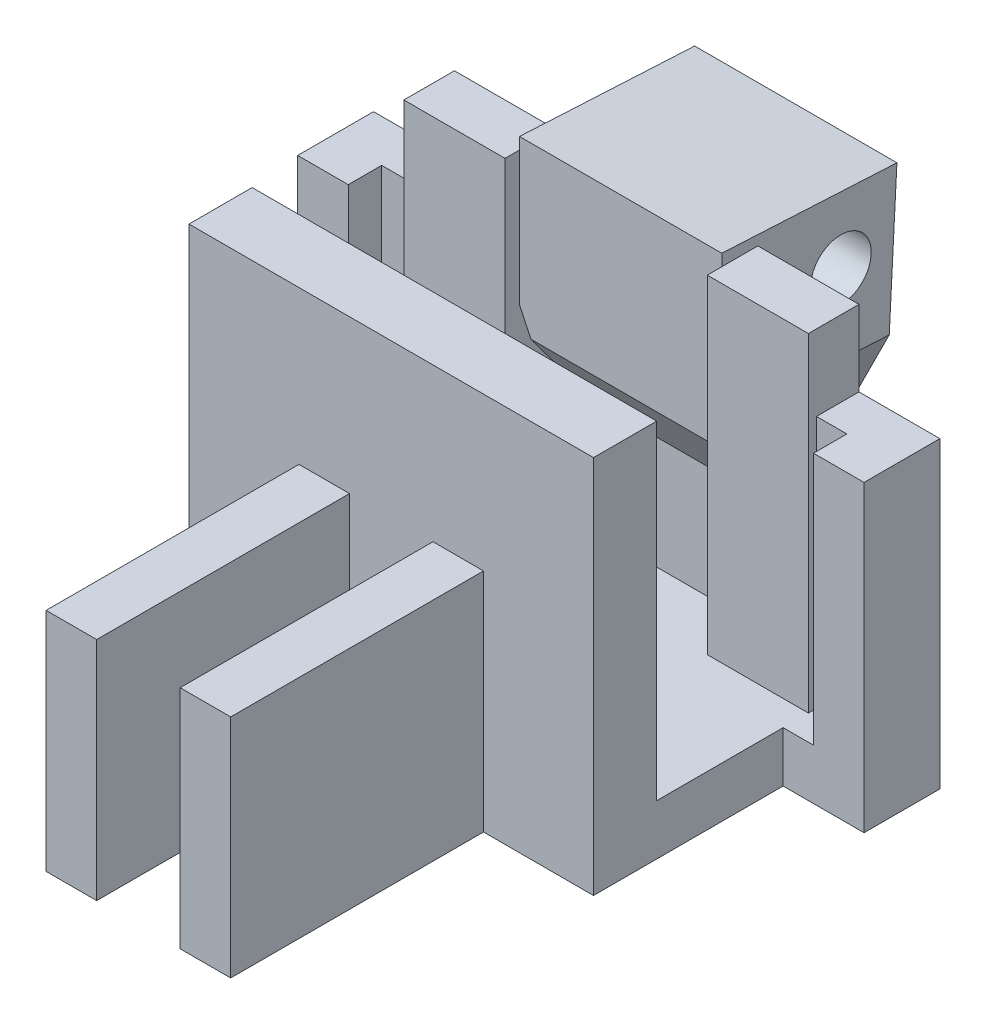
from build123d import *

# Parameters (mm, degrees)
SKETCH_1_W          = 16
SKETCH_1_H          = 6
EXTRUDE_1_DEPTH     = 2
SKETCH_1_3_W        = 16
SKETCH_1_3_H        = 2
SKETCH_1_3_H_2      = 2.5
EXTRUDE_2_DEPTH     = 15
SKETCH_2_W          = 8
SKETCH_2_H          = 26
CUT_EXTRUDE_1_DEPTH = 2
EXTRUDE_3_DEPTH     = 2.5
EXTRUDE_4_DEPTH     = 5
EXTRUDE_5_DEPTH     = 1.5
CUT_EXTRUDE_START   = -6.633865
CUT_EXTRUDE_3_DEPTH = 6.633865
SKETCH_8_R          = 1.2
CUT_EXTRUDE_4_DEPTH = 8
SKETCH_9_W          = 1.2
SKETCH_9_H          = 1.320432063
EXTRUDE_6_DEPTH     = 2
EXTRUDE_7_DEPTH     = 12
SKETCH_10_W         = 2
SKETCH_10_H         = 8.943097661
EXTRUDE_8_DEPTH     = 10


with BuildPart() as part:
    # 草图1 → 凸台-拉伸1 (new body)
    with BuildSketch(Plane(origin=(0, 0, 0), x_dir=(1, 0, 0), z_dir=(0, 1, 0))):
        with Locations((0, 0.25)):
            Rectangle(SKETCH_1_W, SKETCH_1_H)
    extrude(amount=EXTRUDE_1_DEPTH)

    # 草图1<3> → 凸台-拉伸2 (add)
    with BuildSketch(Plane(origin=(0, 0, 0), x_dir=(1, 0, 0), z_dir=(0, 1, 0))):
        with Locations((0, 4.25)):
            Rectangle(SKETCH_1_3_W, SKETCH_1_3_H)
        with Locations((0, -4)):
            Rectangle(SKETCH_1_3_W, SKETCH_1_3_H_2)
    extrude(amount=EXTRUDE_2_DEPTH)

    # 草图2 → 切除-拉伸1 (cut)
    with BuildSketch(Plane(origin=(0, 0, -5.25), x_dir=(-1, 0, 0), z_dir=(0, 0, -1))):
        with Locations((0, 15)):
            Rectangle(SKETCH_2_W, SKETCH_2_H)
    extrude(amount=-CUT_EXTRUDE_1_DEPTH, mode=Mode.SUBTRACT)

    # 草图3 → 凸台-拉伸3 (add, symmetric)
    with BuildSketch(Plane(origin=(0, 0, 0), x_dir=(0, 0, -1), z_dir=(1, 0, 0))):
        Polygon((5.25, 0), (9.953715529, 0), (10.750589922, 15.09810313), (5.25, 15.388422994), align=None)
    extrude(amount=EXTRUDE_3_DEPTH, both=True)

    # 草图5 → 凸台-拉伸4 (add)
    with BuildSketch(Plane(origin=(2.5, 0, 0), x_dir=(0, 0, -1), z_dir=(1, 0, 0))):
        Polygon((5.25, 6.451105389), (3.822798244, 8.744995241), (3.822798244, 15.463750373), (5.25, 15.388422994), align=None)
    extrude(amount=-EXTRUDE_4_DEPTH)

    # 草图6 → 凸台-拉伸5 (add)
    with BuildSketch(Plane.ZY.offset(2.5)):
        Polygon((-5.25, 6.451105389), (-10.280190758, 6.185613084), (-10.750589922, 15.09810313), (-3.822798244, 15.463750373), (-3.822798244, 8.744995241), align=None)
    extrude_5 = extrude(amount=EXTRUDE_5_DEPTH)

    # 草图7 → 切除-拉伸3 (cut)
    with BuildSketch(Plane(origin=(0, -0.523895387, -9.926064452), x_dir=(-1, 0, 0), z_dir=(0, -0.052706408, -0.998610051)).offset(CUT_EXTRUDE_START)):
        Polygon((2.5, 6.718847324), (4, 9.892111055), (4, 6.718847324), align=None)
    cut_extrude_3 = extrude(amount=CUT_EXTRUDE_3_DEPTH, mode=Mode.SUBTRACT)

    # 镜向2: 凸台-拉伸5, 切除-拉伸3 across plane
    add(extrude_5.mirror(Plane(origin=(0, 0, 0), x_dir=(0, 0, 1), z_dir=(1, 0, 0))))
    add(cut_extrude_3.mirror(Plane(origin=(0, 0, 0), x_dir=(0, 0, 1), z_dir=(1, 0, 0))), mode=Mode.SUBTRACT)

    # 草图8 → 切除-拉伸4 (cut)
    with BuildSketch(Plane(origin=(4, 0, 0), x_dir=(0, 0, -1), z_dir=(1, 0, 0))):
        with Locations((8.533675648, 12.541707299)):
            Circle(SKETCH_8_R)
    extrude(amount=-CUT_EXTRUDE_4_DEPTH, mode=Mode.SUBTRACT)

    # 草图9 → 凸台-拉伸6 (add)
    with BuildSketch(Plane.XZ):
        with Locations((8.6, -2.910216032)):
            Rectangle(SKETCH_9_W, SKETCH_9_H)
        with Locations((-8.6, -2.910216032)):
            Rectangle(SKETCH_9_W, SKETCH_9_H)
    extrude(amount=-EXTRUDE_6_DEPTH)

    # 草图9<3> → 凸台-拉伸7 (add)
    with BuildSketch(Plane.XZ):
        Polygon((8, -3.570432063), (8, -5.25), (11.2, -5.25), (11.2, -2.25), (9.2, -2.25), (9.2, -3.570432063), align=None)
        Polygon((-8, -5.25), (-8, -3.570432063), (-9.2, -3.570432063), (-9.2, -2.25), (-11.2, -2.25), (-11.2, -5.25), align=None)
    extrude(amount=-EXTRUDE_7_DEPTH)

    # 草图10 → 凸台-拉伸8 (add)
    with BuildSketch(Plane.XY.offset(5.25)):
        with Locations((2.65, 4.471548831)):
            Rectangle(SKETCH_10_W, SKETCH_10_H)
        with Locations((-2.65, 4.471548831)):
            Rectangle(SKETCH_10_W, SKETCH_10_H)
    extrude(amount=EXTRUDE_8_DEPTH)


solid = part.part
